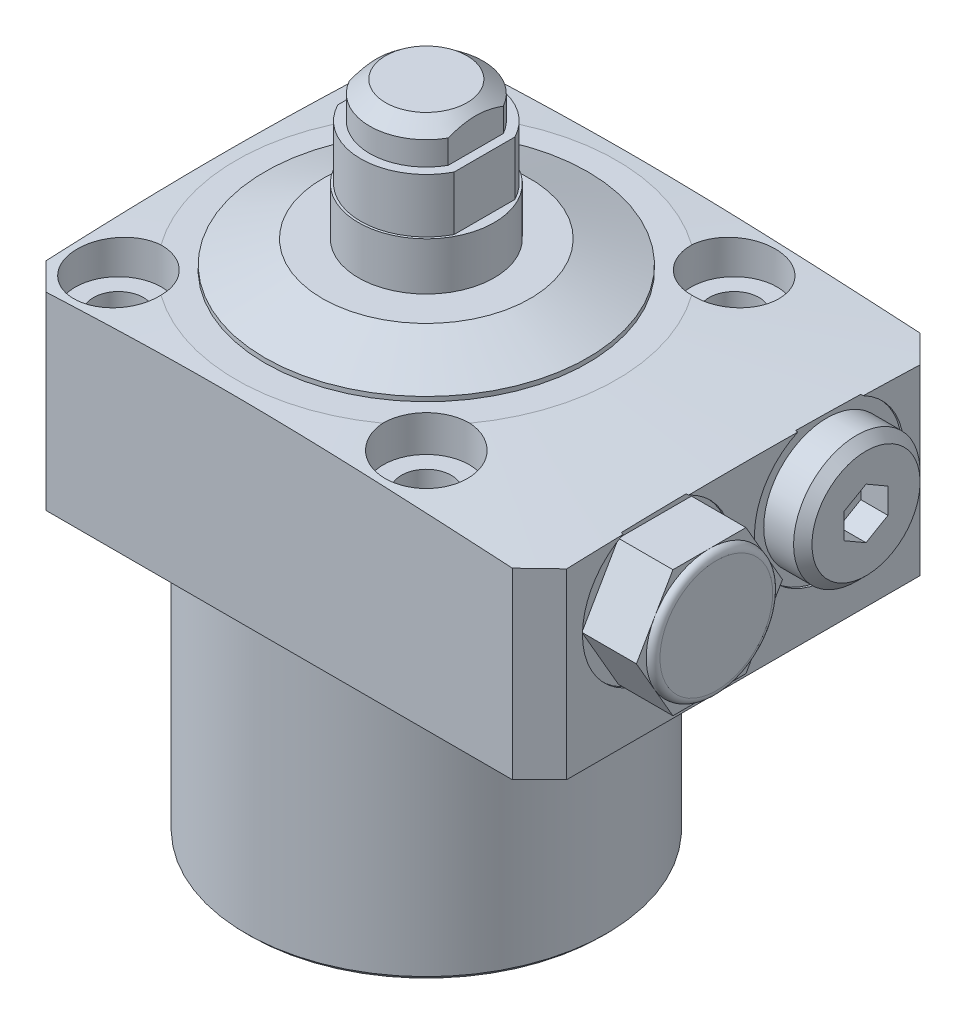
from build123d import *

# Parameters (mm, degrees)
SKETCH2_OUTSIDE_W          = 132.276
SKETCH2_OUTSIDE_H          = 132.276
SKETCH2_OUTSIDE_W_2        = 57.5
SKETCH2_OUTSIDE_H_2        = 45
CUT_EXTRUDE1_DEPTH         = 55
CHAMFER2_SIZE              = 3
CHAMFER1_SIZE              = 1.3714599
CHAMFER1_SIZE2             = 1.754126178
SKETCH5_W                  = 1.79
SKETCH5_H                  = 3.988
CUT_EXTRUDE2_DEPTH         = 23.5
CUT_EXTRUDE2_DEPTH_BACK    = 23.5
SKETCH6_W                  = 1.075
SKETCH6_H                  = 5.98
CUT_EXTRUDE3_DEPTH         = 23.5
CUT_EXTRUDE3_DEPTH_BACK    = 23.5
SKETCH10_R                 = 4.75
CUT_EXTRUDE4_DEPTH         = 4
F_5_5_5_5_DIAMETER_HOLE1_D = 5.5
CIRPATTERN1_COUNT          = 4
CUT_EXTRUDE5_DEPTH         = 3
LPATTERN1_COUNT            = 2
LPATTERN1_PITCH            = 19
SKETCH18_R                 = 1.5
LPATTERN2_COUNT            = 2
LPATTERN2_PITCH            = 19
CHAMFER3_SIZE              = 0.5
FILLET1_R                  = 0.5
BOSS_EXTRUDE1_DEPTH        = 6.78


with BuildPart() as part:
    # Sketch1 → Revolve1 (revolve)
    with BuildSketch(Plane.XY, mode=Mode.PRIVATE) as revolve1_sk:
        Polygon((-19.925, 0), (-50, 0), (-50, 19.472122454), (-21, 21.5), (0, 21.5), (0, -32.5), (-19.925, -32.5), align=None)
    revolve(revolve1_sk.sketch.rotate(Axis((0, 0, 0), (0, -1, 0)), 270), axis=Axis((0, 0, 0), (0, -1, 0)))  # turned: the seam where the file's is

    # Sketch2 outside → Cut-Extrude1 (cut, through all)
    with BuildSketch(Plane(origin=(0, 21.5, 0), x_dir=(1, 0, 0), z_dir=(0, 1, 0))):
        Rectangle(SKETCH2_OUTSIDE_W, SKETCH2_OUTSIDE_H)
        with Locations((6.25, 0)):
            Rectangle(SKETCH2_OUTSIDE_W_2, SKETCH2_OUTSIDE_H_2, mode=Mode.SUBTRACT)
    extrude(amount=-CUT_EXTRUDE1_DEPTH, mode=Mode.SUBTRACT)

    # Chamfer2
    chamfer2_edges = [part.edges().sort_by_distance(p)[0] for p in [
        (-22.5, 10.37170276, -22.5),
        (35, 10.029463905, -22.5),
        (35, 10.029463905, 22.5),
        (-22.5, 10.37170276, 22.5),
    ]]
    chamfer(chamfer2_edges, length=CHAMFER2_SIZE)

    # Sketch4 → Revolve2 (revolve)
    with BuildSketch(Plane.XY, mode=Mode.PRIVATE) as revolve2_sk:
        Polygon((0, 39.75), (-6.25, 39.75), (-6.25, 35.762), (-7.25, 35.762), (-7.25, 29.782), (-7.5, 29.782), (-7.5, 21.5), (0, 21.5), align=None)
    revolve(revolve2_sk.sketch.rotate(Axis((0, 0, 0), (0, 1, 0)), 270), axis=Axis((0, 0, 0), (0, 1, 0)))  # turned: the seam where the file's is

    # Chamfer1
    chamfer1_edges = [part.edges().sort_by_distance(p)[0] for p in [
        (0, 39.75, 6.25),
    ]]
    chamfer1_side = [part.faces().sort_by_distance(p)[0] for p in [
        (0, 37.756, 6.25),
    ]]
    chamfer(chamfer1_edges, length=CHAMFER1_SIZE, length2=CHAMFER1_SIZE2, reference=chamfer1_side[0])

    # Sketch5 → Cut-Extrude2 (cut, two sides)
    with BuildSketch(Plane.XY) as cut_extrude2_sk:
        with Locations((-6.355, 37.756)):
            Rectangle(SKETCH5_W, SKETCH5_H)
        with Locations((6.355, 37.756)):
            Rectangle(SKETCH5_W, SKETCH5_H)
    extrude(amount=CUT_EXTRUDE2_DEPTH, mode=Mode.SUBTRACT)
    extrude(cut_extrude2_sk.sketch, amount=-CUT_EXTRUDE2_DEPTH_BACK, mode=Mode.SUBTRACT)

    # Sketch6 → Cut-Extrude3 (cut, two sides)
    with BuildSketch(Plane.XY) as cut_extrude3_sk:
        with Locations((-6.9625, 32.772)):
            Rectangle(SKETCH6_W, SKETCH6_H)
        with Locations((6.9625, 32.772)):
            Rectangle(SKETCH6_W, SKETCH6_H)
    extrude(amount=CUT_EXTRUDE3_DEPTH, mode=Mode.SUBTRACT)
    extrude(cut_extrude3_sk.sketch, amount=-CUT_EXTRUDE3_DEPTH_BACK, mode=Mode.SUBTRACT)

    # Sketch10 → Cut-Extrude4 (cut)
    with BuildSketch(Plane(origin=(0, 21.5, 0), x_dir=(1, 0, 0), z_dir=(0, 1, 0))):
        with Locations(Location((-17, 17, 0), (0, 0, 269.316686409))):  # turned: the seam where the file's is
            Circle(SKETCH10_R)
    cut_extrude4 = extrude(amount=-CUT_EXTRUDE4_DEPTH, mode=Mode.SUBTRACT)

    # Ø5.5 (5.5) Diameter Hole1 (through all)
    with Locations(Plane(origin=(-17, 17.5, -17), x_dir=(0, 0, 1), z_dir=(0, 1, 0))):
        with Locations((0, 0)):
            f_5_5_5_5_diameter_hole1 = Hole(F_5_5_5_5_DIAMETER_HOLE1_D / 2)

    # CirPattern1: Cut-Extrude4, Ø5.5 (5.5) Diameter Hole1 ×4 about axis
    cirpattern1_axis = Axis((0, 0, 0), (0, 1, 0))
    add([cut_extrude4.rotate(cirpattern1_axis, i * 360 / CIRPATTERN1_COUNT) for i in range(1, CIRPATTERN1_COUNT)], mode=Mode.SUBTRACT)
    add([f_5_5_5_5_diameter_hole1.rotate(cirpattern1_axis, i * 360 / CIRPATTERN1_COUNT) for i in range(1, CIRPATTERN1_COUNT)], mode=Mode.SUBTRACT)

    # Sketch12 → Cut-Revolve2 (revolve, cut)
    with BuildSketch(Plane.XY.offset(-9.5), mode=Mode.PRIVATE) as cut_revolve2_sk:
        Polygon((35, 21.255), (34.75, 21.255), (34.75, 17.953), (34.2166, 17.4196), (24.1836, 17.4196), (21.528036408, 13), (35, 13), align=None)
    cut_revolve2 = revolve(cut_revolve2_sk.sketch.rotate(Axis((17.95729386, 13, -9.5), (1, 0, 0)), 90), axis=Axis((17.95729386, 13, -9.5), (1, 0, 0)), mode=Mode.SUBTRACT)  # turned: the seam where the file's is

    # Sketch13 → Revolve3 (revolve)
    with BuildSketch(Plane.XY.offset(-9.5), mode=Mode.PRIVATE) as revolve3_sk:
        Polygon((34.75, 19.985), (38.045, 19.985), (39.06, 18.97), (39.06, 13), (34.75, 13), align=None)
    revolve(revolve3_sk.sketch.rotate(Axis((10.466346838, 13, -9.5), (1, 0, 0)), 90), axis=Axis((10.466346838, 13, -9.5), (1, 0, 0)))  # turned: the seam where the file's is

    # Sketch14 → Cut-Extrude5 (cut)
    with BuildSketch(Plane(origin=(39.06, 0, 0), x_dir=(0, 0, -1), z_dir=(1, 0, 0))):
        Polygon((11.9255, 11.599636922), (11.9255, 14.400363078), (9.5, 15.800726156), (7.0745, 14.400363078), (7.0745, 11.599636922), (9.5, 10.199273844), align=None)
    cut_extrude5 = extrude(amount=-CUT_EXTRUDE5_DEPTH, mode=Mode.SUBTRACT)

    # Sketch16 → Cut-Revolve4 (revolve, cut)
    with BuildSketch(Plane(origin=(9.5, 0, -9.5), x_dir=(-1, 0, 0), z_dir=(0, 0, -1)), mode=Mode.PRIVATE) as cut_revolve4_sk:
        Polygon((-17.5, 13.502151548), (-20, 12), (-20, 2.875), (-20.625, 2.25), (-22.5, 2.25), (-22.5, 0), (-17.5, 0), align=None)
    cut_revolve4 = revolve(cut_revolve4_sk.sketch.rotate(Axis((27, -1.224048676, -9.5), (0, -1, 0)), 180), axis=Axis((27, -1.224048676, -9.5), (0, -1, 0)), mode=Mode.SUBTRACT)  # turned: the seam where the file's is

    # LPattern1: Cut-Revolve2, Cut-Extrude5, Cut-Revolve4 ×2
    with Locations(*[(0, 0, i * LPATTERN1_PITCH) for i in range(1, LPATTERN1_COUNT)]):
        add(cut_revolve2, mode=Mode.SUBTRACT)
        add(cut_extrude5, mode=Mode.SUBTRACT)
        add(cut_revolve4, mode=Mode.SUBTRACT)

    # Chamfer3
    chamfer3_edges = [part.edges().sort_by_distance(p)[0] for p in [
        (0, -32.5, -19.925),
    ]]
    chamfer(chamfer3_edges, length=CHAMFER3_SIZE)

    # Fillet1
    fillet1_edges = [part.edges().sort_by_distance(p)[0] for p in [
        (0, 0, -19.925),
    ]]
    fillet(fillet1_edges, radius=FILLET1_R)

    # Sketch19 → Revolve5 (revolve)
    with BuildSketch(Plane.XY, mode=Mode.PRIVATE) as revolve5_sk:
        Polygon((7.5, 21.5), (17.82, 21.5), (17.82, 22), (11.473380261, 24.5), (7.5, 24.5), align=None)
    revolve(revolve5_sk.sketch.rotate(Axis((0, 29.782, 0), (0, -1, 0)), 270), axis=Axis((0, 29.782, 0), (0, -1, 0)))  # turned: the seam where the file's is

    # Sketch20 → Boss-Extrude1 (add)
    with BuildSketch(Plane(origin=(34.75, 0, 0), x_dir=(0, 0, -1), z_dir=(1, 0, 0))):
        Polygon((-1.434416739, 13), (-5.46720837, 19.985), (-13.53279163, 19.985), (-17.565583261, 13), (-13.53279163, 6.015), (-5.46720837, 6.015), align=None)
    extrude(amount=BOSS_EXTRUDE1_DEPTH)

    # Sketch21 → Cut-Revolve5 (revolve, cut)
    with BuildSketch(Plane(origin=(0, 0, 9.5), x_dir=(-1, 0, 0), z_dir=(0, 0, -1)), mode=Mode.PRIVATE) as cut_revolve5_sk:
        with BuildLine():
            Line((-41.53, 19.223), (-44.805969605, 19.223))
            Line((-44.805969605, 19.223), (-44.805969605, 23.173767546))
            Line((-44.805969605, 23.173767546), (-40.768, 23.173767546))
            Line((-40.768, 23.173767546), (-40.768, 19.985))
            ThreePointArc((-40.768, 19.985), (-41.306815367, 19.761815367), (-41.53, 19.223))
        make_face()
    revolve(cut_revolve5_sk.sketch.rotate(Axis((17.95729386, 13, 9.5), (-1, 0, 0)), 90), axis=Axis((17.95729386, 13, 9.5), (-1, 0, 0)), mode=Mode.SUBTRACT)  # turned: the seam where the file's is


with BuildPart() as body_2:
    # Sketch18 → Revolve4 (revolve)
    with BuildSketch(Plane(origin=(-9.5, 0, -9.5), x_dir=(1, 0, 0), z_dir=(0, 0, 1))):
        with Locations((33.001, 0.74999)):
            Circle(SKETCH18_R)
    revolve(axis=Axis((27, -2.585671099, -9.5), (0, -1, 0)))


with BuildPart() as lpattern2_1:
    # LPattern2: pattern copy
    add(body_2.part.moved(Location(Vector(0, 0, 1) * (1 * LPATTERN2_PITCH))))


solid = Compound([part.part, body_2.part, lpattern2_1.part])
